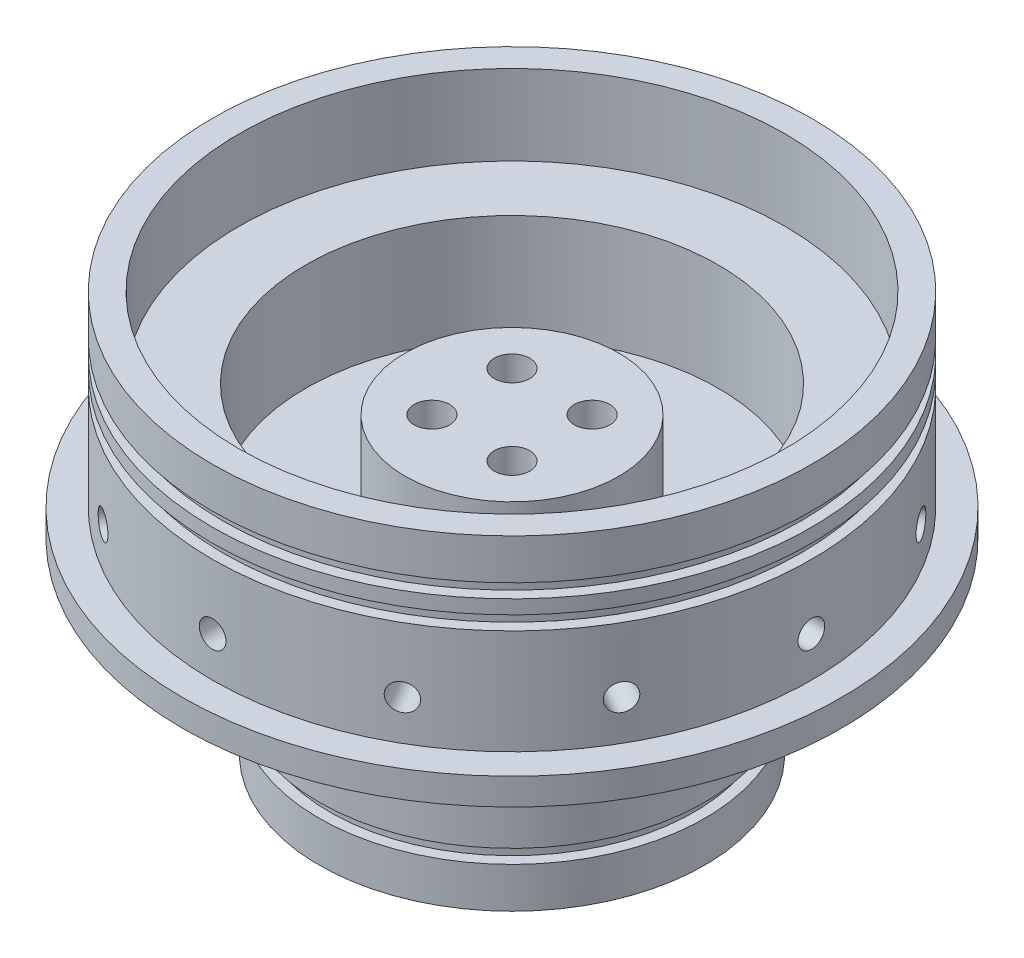
from build123d import *

# Parameters (mm, degrees)
SKETCH1_R              = 78.359
BULKHEADPLATE_DEPTH    = 6.35
SKETCH3_R              = 71.247
SKETCH3_R_2            = 49.022
NOSBASE_DEPTH          = 25.4
SKETCH4_R              = 71.247
SKETCH4_R_2            = 64.897
NOSORINGS_DEPTH        = 19.05
SKETCH5_R              = 45.847
SKETCH5_R_2            = 23.622
ENGINEBASE_DEPTH       = 25.4
SKETCH6_R              = 45.847
SKETCH6_R_2            = 39.497
ENGINEORINGS_DEPTH     = 19.05
SKETCH7_R              = 3.175
NOSBOLTHOLE_DEPTH      = 12.7
NOSBOLTHOLES_COUNT     = 12
SKETCH13_W             = 2.54
SKETCH13_H             = 3.302
SKETCH11_R             = 2.413
ENGINEBOLTHOLE_DEPTH   = 12.7
ENGINEBOLTHOLES_COUNT  = 12
SKETCH12_W             = 2.54
SKETCH12_H             = 3.302
SKETCH17_R             = 25.4
INJECTORMANIFOLD_DEPTH = 19.05
INJECTORTAPS_D         = 8.4328
INJECTORTAPS_DEPTH     = 12.7
INJECTORTAPS_TIP       = 2.533468714
CNVATAPS_D             = 8.4328
CNVATAPS_DEPTH         = 12.7
CNVATAPS_TIP           = 2.533468714


with BuildPart() as part:
    # Sketch1 → BulkheadPlate (new body)
    with BuildSketch(Plane(origin=(0, 0, 0), x_dir=(1, 0, 0), z_dir=(0, 1, 0))):
        Circle(SKETCH1_R)
    extrude(amount=BULKHEADPLATE_DEPTH)

    # Sketch3 → NosBase (add)
    with BuildSketch(Plane(origin=(0, 6.35, 0), x_dir=(1, 0, 0), z_dir=(0, 1, 0))):
        Circle(SKETCH3_R)
        Circle(SKETCH3_R_2, mode=Mode.SUBTRACT)
    extrude(amount=NOSBASE_DEPTH)

    # Sketch4 → NosORings (add)
    with BuildSketch(Plane(origin=(0, 31.75, 0), x_dir=(1, 0, 0), z_dir=(0, 1, 0))):
        Circle(SKETCH4_R)
        Circle(SKETCH4_R_2, mode=Mode.SUBTRACT)
    extrude(amount=NOSORINGS_DEPTH)

    # Sketch5 → EngineBase (add)
    with BuildSketch(Plane.XZ):
        Circle(SKETCH5_R)
        Circle(SKETCH5_R_2, mode=Mode.SUBTRACT)
    extrude(amount=ENGINEBASE_DEPTH)

    # Sketch6 → EngineORings (add)
    with BuildSketch(Plane(origin=(0, -25.4, 0), x_dir=(-1, 0, 0), z_dir=(0, -1, 0))):
        Circle(SKETCH6_R)
        Circle(SKETCH6_R_2, mode=Mode.SUBTRACT)
    extrude(amount=ENGINEORINGS_DEPTH)

    # Sketch7 → NosBoltHole (cut)
    with BuildSketch(Plane.XY.offset(71.247)):
        with Locations((0, 15.891824388)):
            Circle(SKETCH7_R)
    nosbolthole = extrude(amount=-NOSBOLTHOLE_DEPTH, mode=Mode.SUBTRACT)

    # NosBoltHoles: NosBoltHole ×12 about axis
    nosboltholes_axis = Axis((0, 0, 0), (0, 1, 0))
    for i in range(1, NOSBOLTHOLES_COUNT):
        add(nosbolthole.rotate(nosboltholes_axis, i * 360 / NOSBOLTHOLES_COUNT), mode=Mode.SUBTRACT)

    # Sketch13 → NosORingChannel (revolve, cut)
    with BuildSketch(Plane.XY):
        with Locations((-69.977, 39.497)):
            Rectangle(SKETCH13_W, SKETCH13_H)
        with Locations((-69.977, 32.893)):
            Rectangle(SKETCH13_W, SKETCH13_H)
    revolve(axis=Axis((0, 0, 0), (0, 1, 0)), mode=Mode.SUBTRACT)

    # Sketch11 → EngineBoltHole (cut)
    with BuildSketch(Plane.XY.offset(45.847)):
        with Locations((0, -7.62)):
            Circle(SKETCH11_R)
    enginebolthole = extrude(amount=-ENGINEBOLTHOLE_DEPTH, mode=Mode.SUBTRACT)

    # EngineBoltHoles: EngineBoltHole ×12 about axis
    engineboltholes_axis = Axis((0, 0, 0), (0, 1, 0))
    for i in range(1, ENGINEBOLTHOLES_COUNT):
        add(enginebolthole.rotate(engineboltholes_axis, i * 360 / ENGINEBOLTHOLES_COUNT), mode=Mode.SUBTRACT)

    # Sketch12 → EngineORingChannel (revolve, cut)
    with BuildSketch(Plane.XY):
        with Locations((-44.577, -33.147)):
            Rectangle(SKETCH12_W, SKETCH12_H)
    revolve(axis=Axis((0, 0, 0), (0, -1, 0)), mode=Mode.SUBTRACT)

    # Sketch17 → InjectorManifold (add)
    with BuildSketch(Plane(origin=(0, 6.35, 0), x_dir=(1, 0, 0), z_dir=(0, 1, 0))):
        Circle(SKETCH17_R)
    extrude(amount=INJECTORMANIFOLD_DEPTH)

    # InjectorTaps
    with Locations(Plane(origin=(0, 0, 0), x_dir=(-1, 0, 0), z_dir=(0, -1, 0))):
        with Locations((-9.525, 9.525), (9.525, 9.525), (9.525, -9.525), (-9.525, -9.525)):
            Hole(INJECTORTAPS_D / 2, depth=INJECTORTAPS_DEPTH)
            with Locations((0, 0, -(INJECTORTAPS_DEPTH + INJECTORTAPS_TIP / 2))):  # 118° drill point
                Cone(0, INJECTORTAPS_D / 2, INJECTORTAPS_TIP, mode=Mode.SUBTRACT)

    # CNVATaps
    with Locations(Plane(origin=(0, 25.4, 0), x_dir=(1, 0, 0), z_dir=(0, 1, 0))):
        with Locations((-9.525, 9.525), (9.525, 9.525), (9.525, -9.525), (-9.525, -9.525)):
            Hole(CNVATAPS_D / 2, depth=CNVATAPS_DEPTH)
            with Locations((0, 0, -(CNVATAPS_DEPTH + CNVATAPS_TIP / 2))):  # 118° drill point
                Cone(0, CNVATAPS_D / 2, CNVATAPS_TIP, mode=Mode.SUBTRACT)


solid = part.part
